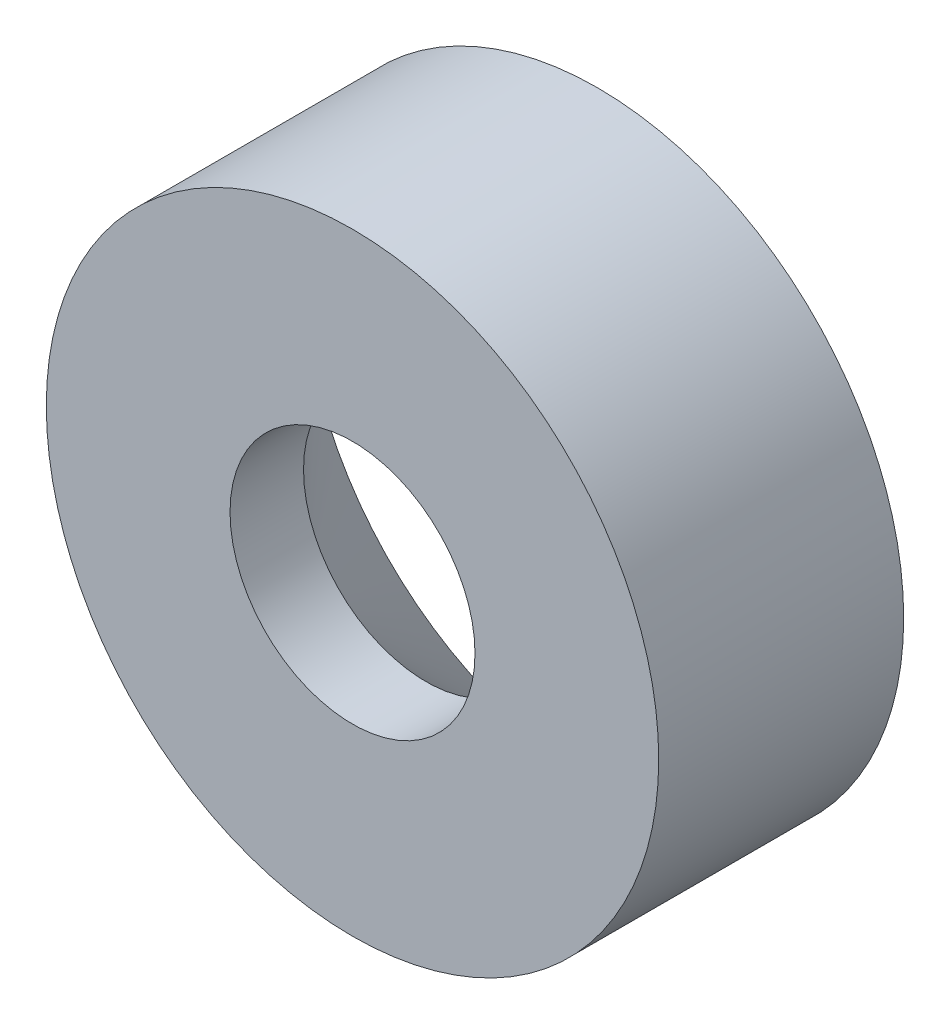
from build123d import *

# Parameters (mm, degrees)
SKETCH_1_R          = 12.5
EXTRUDE_1_DEPTH     = 10
SKETCH_3_R          = 5
CUT_EXTRUDE_1_DEPTH = 11
CHAMFER_1_SIZE      = 7


with BuildPart() as part:
    # ｽｹｯﾁ1 → ﾎﾞｽ - 押し出し1 (new body)
    with BuildSketch(Plane.XY):
        Circle(SKETCH_1_R)
    extrude(amount=EXTRUDE_1_DEPTH)

    # ｽｹｯﾁ3 → ｶｯﾄ - 押し出し1 (cut, through all)
    with BuildSketch(Plane(origin=(0, 0, 0), x_dir=(-1, 0, 0), z_dir=(0, 0, -1))):
        Circle(SKETCH_3_R)
    extrude(amount=-CUT_EXTRUDE_1_DEPTH, mode=Mode.SUBTRACT)

    # 面取り1
    chamfer_1_edges = [part.edges().sort_by_distance(p)[0] for p in [
        (5, 0, 0),
    ]]
    chamfer(chamfer_1_edges, length=CHAMFER_1_SIZE)


solid = part.part
